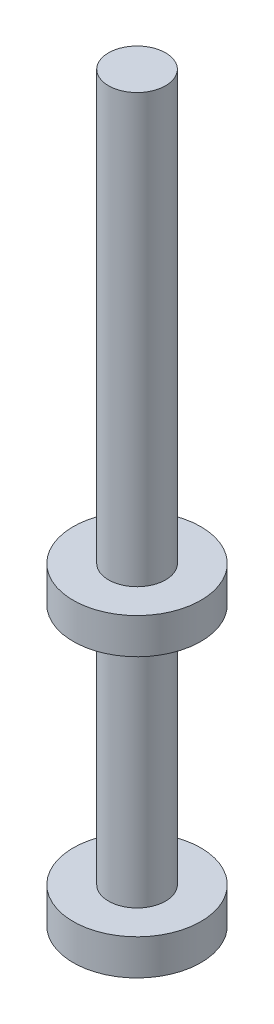
from build123d import *


with BuildPart() as part:
    # Esboço1 → Revolução1 (revolve)
    with BuildSketch(Plane.XY):
        Polygon((0, 75), (4, 75), (4, 15), (8.95, 15), (8.95, 10), (4, 10), (4, -24), (8.95, -24), (8.95, -29), (4, -29), (4, -31), (0, -31), align=None)
    revolve(axis=Axis((0, 0, 0), (0, 1, 0)))


solid = part.part
